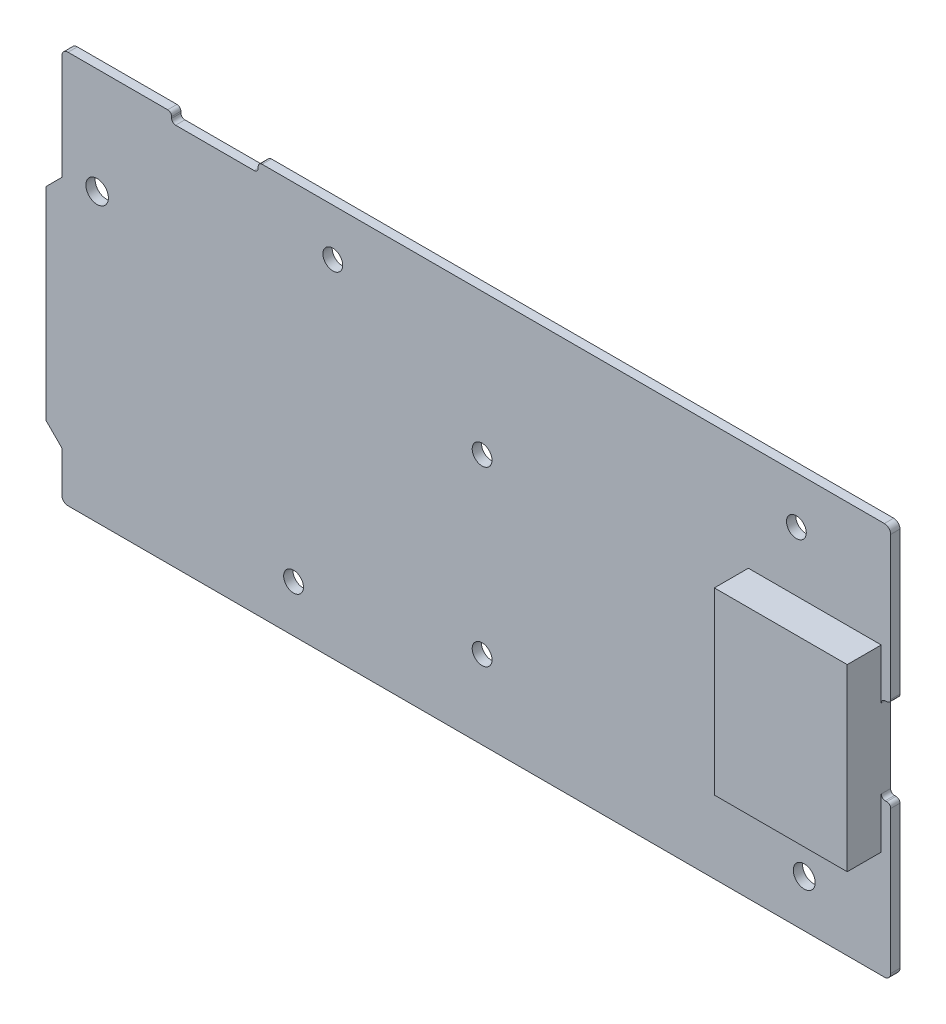
from build123d import *

# Parameters (mm, degrees)
ESBO_O2_R                = 1.820066551
ESBO_O2_R_2              = 1.6002
ESBO_O2_R_3              = 1.768261329
RESSALTO_EXTRUS_O1_DEPTH = 1.5
ARQUIVOS_LOCAIS1_R       = 1.5
RESSALTO_EXTRUS_O2_DEPTH = 2.5
ARQUIVOS_LOCAIS2_W       = 12
ARQUIVOS_LOCAIS2_H       = 6.934834447
RESSALTO_EXTRUS_O3_DEPTH = 0.2
ARQUIVOS_LOCAIS3_W       = 21.475999934
ARQUIVOS_LOCAIS3_H       = 29
RESSALTO_EXTRUS_O4_DEPTH = 5.5


with BuildPart() as part:
    # Esboço2 → Ressalto-extrusão1 (new body)
    with BuildSketch(Plane.XY):
        with BuildLine():
            Line((66.770810212, -1.788001123), (66.516852098, -1.788001123))
            ThreePointArc((66.516852098, -1.788001123), (66.067836522, -1.601984783), (65.881852046, -1.152956008))
            Line((65.881852046, -1.152956008), (65.881852046, 11.567000327))
            ThreePointArc((65.881852046, 11.567000327), (66.067868997, 12.016014785), (66.516897161, 12.20199865))
            Line((66.516897161, 12.20199865), (66.770852104, 12.20199865))
            ThreePointArc((66.770852104, 12.20199865), (67.219867652, 12.38801502), (67.405852112, 12.837043786))
            Line((67.405852112, 12.837043786), (67.405852112, 35.941000874))
            ThreePointArc((67.405852112, 35.941000874), (67.107342698, 36.659508424), (66.388413427, 36.957000731))
            Line((66.388413427, 36.957000731), (-34.193146911, 36.957000731))
            ThreePointArc((-34.193146911, 36.957000731), (-34.642164318, 36.770979998), (-34.82814905, 36.321947678))
            Line((-34.82814905, 36.321947678), (-34.82814905, 36.068000792))
            ThreePointArc((-34.82814905, 36.068000792), (-35.014158502, 35.618987038), (-35.463182564, 35.43300247))
            Line((-35.463182564, 35.43300247), (-48.183144777, 35.43300247))
            ThreePointArc((-48.183144777, 35.43300247), (-48.632160998, 35.619010573), (-48.818146915, 36.068035984))
            Line((-48.818146915, 36.068035984), (-48.818146915, 36.322002409))
            ThreePointArc((-48.818146915, 36.322002409), (-49.004168997, 36.771017349), (-49.453199968, 36.957000732))
            Line((-49.453199968, 36.957000732), (-65.563142032, 36.957000732))
            ThreePointArc((-65.563142032, 36.957000732), (-66.281654952, 36.658489436), (-66.57914953, 35.939554956))
            Line((-66.57914953, 35.939554956), (-66.57914953, 18.923000336))
            Line((-66.57914953, 18.923000336), (-69.119142817, 16.38299942))
            Line((-69.119142817, 16.38299942), (-69.119142817, -16.38299942))
            Line((-69.119142817, -16.38299942), (-66.57914953, -18.922999382))
            Line((-66.57914953, -18.922999382), (-66.57914953, -25.526999235))
            ThreePointArc((-66.57914953, -25.526999235), (-66.280636326, -26.245507951), (-65.561704328, -26.543000285))
            Line((-65.561704328, -26.543000285), (66.389851048, -26.543000285))
            ThreePointArc((66.389851048, -26.543000285), (67.108359334, -26.244491656), (67.405852096, -25.525562163))
            Line((67.405852096, -25.525562163), (67.405852096, -2.422999446))
            ThreePointArc((67.405852096, -2.422999446), (67.219837234, -1.973985183), (66.770810212, -1.788001123))
        make_face()
        with Locations((-60.86414892, 19.812000732)):
            Circle(ESBO_O2_R, mode=Mode.SUBTRACT)
        with Locations((-22.76414892, 29.336990572)):
            Circle(ESBO_O2_R_2, mode=Mode.SUBTRACT)
        with Locations((1.36585108, 14.097000732)):
            Circle(ESBO_O2_R_2, mode=Mode.SUBTRACT)
        with Locations((-29.11414892, -18.922999268)):
            Circle(ESBO_O2_R_2, mode=Mode.SUBTRACT)
        with Locations((1.36585108, -13.842999268)):
            Circle(ESBO_O2_R_2, mode=Mode.SUBTRACT)
        with Locations((52.16585108, 29.337000732)):
            Circle(ESBO_O2_R_2, mode=Mode.SUBTRACT)
        with Locations((53.43585108, -18.922999268)):
            Circle(ESBO_O2_R_3, mode=Mode.SUBTRACT)
    extrude(amount=RESSALTO_EXTRUS_O1_DEPTH)

    # Arquivos locais1 → Ressalto-extrusão2 (add)
    with BuildSketch(Plane(origin=(0, 0, 0), x_dir=(-1, 0, 0), z_dir=(0, 0, -1))):
        with Locations((43.07914953, -13.043000285)):
            Circle(ARQUIVOS_LOCAIS1_R)
        with Locations((53.57914953, -13.043000285)):
            Circle(ARQUIVOS_LOCAIS1_R)
        with Locations((43.07914953, -22.043000285)):
            Circle(ARQUIVOS_LOCAIS1_R)
        with Locations((53.57914953, -22.043000285)):
            Circle(ARQUIVOS_LOCAIS1_R)
    extrude(amount=RESSALTO_EXTRUS_O2_DEPTH)

    # Arquivos locais2 → Ressalto-extrusão3 (add)
    with BuildSketch(Plane(origin=(0, 0, 0), x_dir=(-1, 0, 0), z_dir=(0, 0, -1))):
        with Locations((60.57914953, 28.424417956)):
            Rectangle(ARQUIVOS_LOCAIS2_W, ARQUIVOS_LOCAIS2_H)
    extrude(amount=RESSALTO_EXTRUS_O3_DEPTH)

    # Arquivos locais3 → Ressalto-extrusão4 (add)
    with BuildSketch(Plane.XY.offset(1.5)):
        with Locations((55.143852079, 5.20702216)):
            Rectangle(ARQUIVOS_LOCAIS3_W, ARQUIVOS_LOCAIS3_H)
    extrude(amount=RESSALTO_EXTRUS_O4_DEPTH)


solid = part.part
